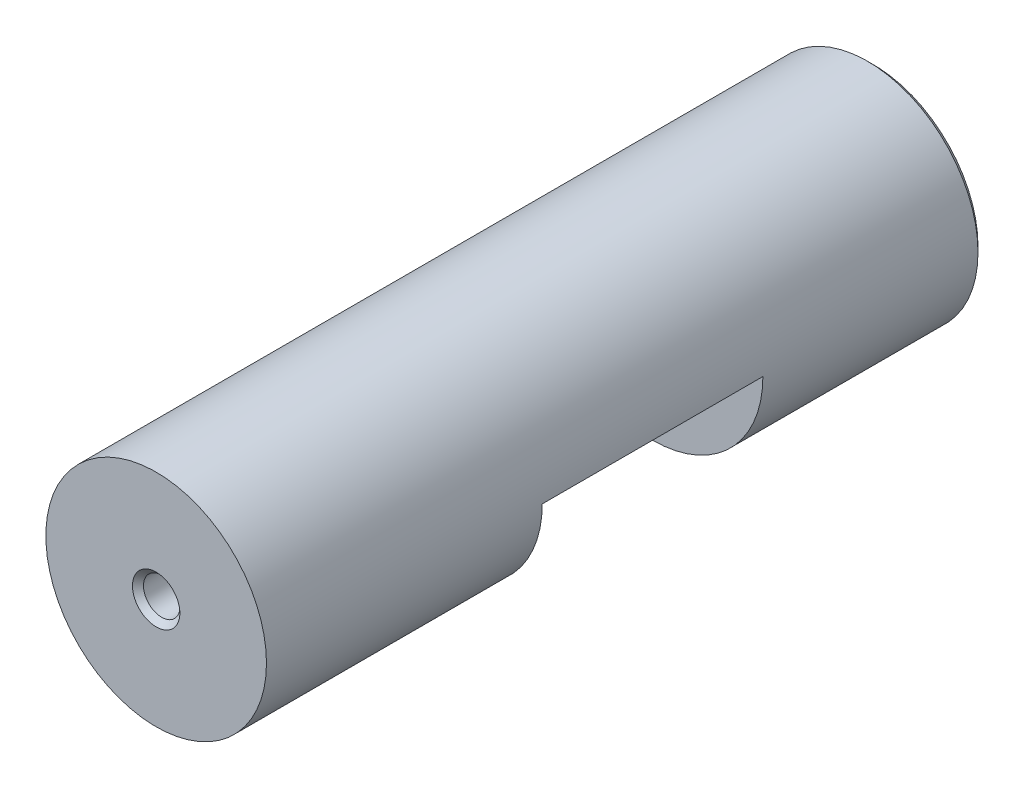
from build123d import *

# Parameters (mm, degrees)
SKETCH1_R           = 10
BOSS_EXTRUDE1_DEPTH = 65
SKETCH2_R           = 1.65
CUT_EXTRUDE1_DEPTH  = 15
CHAMFER1_SIZE       = 0.5
SKETCH3_R           = 5
CUT_EXTRUDE2_DEPTH  = 15
CHAMFER2_SIZE       = 0.5
CHAMFER3_SIZE       = 0.5
SKETCH4_W           = 24.548279796
SKETCH4_H           = 20
CUT_EXTRUDE3_DEPTH  = 13


with BuildPart() as part:
    # Sketch1 → Boss-Extrude1 (new body)
    with BuildSketch(Plane.XY):
        Circle(SKETCH1_R)
    extrude(amount=BOSS_EXTRUDE1_DEPTH)

    # Sketch2 → Cut-Extrude1 (cut)
    with BuildSketch(Plane.XY.offset(65)):
        Circle(SKETCH2_R)
    extrude(amount=-CUT_EXTRUDE1_DEPTH, mode=Mode.SUBTRACT)

    # Chamfer1
    chamfer1_edges = [part.edges().sort_by_distance(p)[0] for p in [
        (-1.65, 0, 65),
    ]]
    chamfer(chamfer1_edges, length=CHAMFER1_SIZE)

    # Sketch3 → Cut-Extrude2 (cut)
    with BuildSketch(Plane(origin=(0, 0, 0), x_dir=(-1, 0, 0), z_dir=(0, 0, -1))):
        Circle(SKETCH3_R)
    extrude(amount=-CUT_EXTRUDE2_DEPTH, mode=Mode.SUBTRACT)

    # Chamfer2
    chamfer2_edges = [part.edges().sort_by_distance(p)[0] for p in [
        (5, 0, 0),
    ]]
    chamfer(chamfer2_edges, length=CHAMFER2_SIZE)

    # Chamfer3
    chamfer3_edges = [part.edges().sort_by_distance(p)[0] for p in [
        (-10, 0, 0),
    ]]
    chamfer(chamfer3_edges, length=CHAMFER3_SIZE)

    # Sketch4 → Cut-Extrude3 (cut)
    with BuildSketch(Plane(origin=(0, 0, 0), x_dir=(1, 0, 0), z_dir=(0, 1, 0))):
        with Locations((0.075917463, -30)):
            Rectangle(SKETCH4_W, SKETCH4_H)
    extrude(amount=-CUT_EXTRUDE3_DEPTH, mode=Mode.SUBTRACT)


solid = part.part
